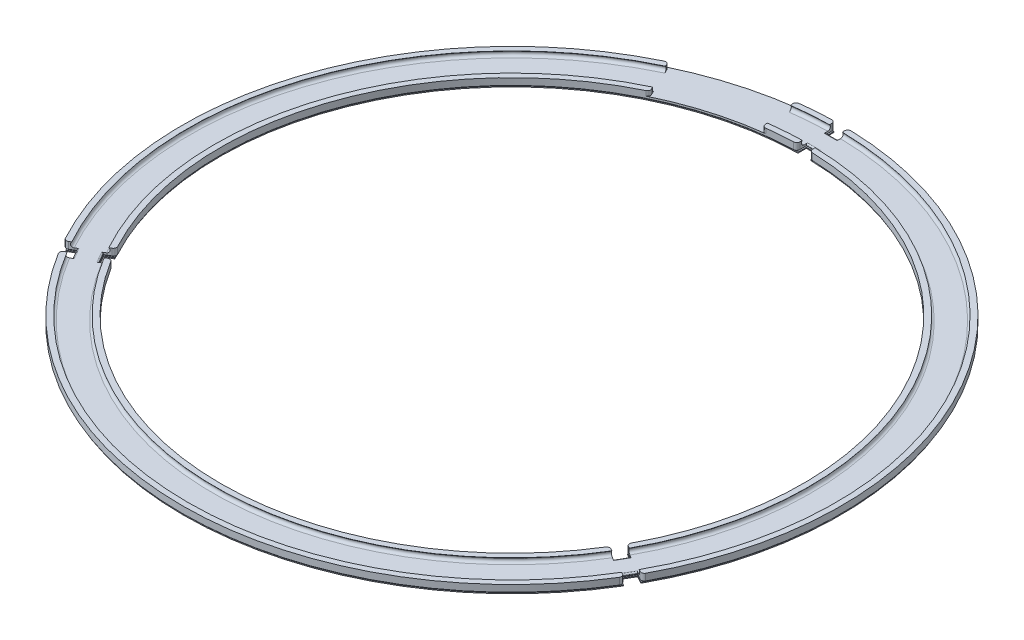
from build123d import *
from build123d.topology import SkipClean

# Parameters (mm, degrees)
CHAMFER1_SIZE                = 0.4
SKETCH10_R                   = 102.8
SKETCH10_R_2                 = 91.6
BOSS_EXTRUDE2_DEPTH          = 0.3
CUT_EXTRUDE5_DEPTH           = 146.962675023
FILLET4_R                    = 1
CHAMFER2_SIZE                = 0.4
FILLET6_R                    = 0.4
CIRPATTERN3_COUNT            = 3
FILLET4_OF_CIRPATTERN3_R     = 1
CHAMFER2_OF_CIRPATTERN3_SIZE = 0.4
FILLET6_OF_CIRPATTERN3_R     = 0.4
CUT_EXTRUDE6_DEPTH           = 146.954547721
FILLET5_R                    = 1


with BuildPart() as part:
    # Sketch1 → Revolve1 (revolve)
    with BuildSketch(Plane.XY, mode=Mode.PRIVATE) as revolve1_sk:
        with BuildLine():
            Line((91.2, 0.65), (92.952277442, 0.65))
            ThreePointArc((92.952277442, 0.65), (92.701564029, -0.291547595), (93.5, -0.85))
            Line((93.5, -0.85), (100.9, -0.85))
            ThreePointArc((100.9, -0.85), (101.698435971, -0.291547595), (101.447722558, 0.65))
            Line((101.447722558, 0.65), (103.2, 0.65))
            Line((103.2, 0.65), (103.2, -1.85))
            Line((103.2, -1.85), (91.2, -1.85))
            Line((91.2, -1.85), (91.2, 0.65))
        make_face()
    revolve(revolve1_sk.sketch.rotate(Axis((0, 52.631578947, 0), (0, -1, 0)), 90), axis=Axis((0, 52.631578947, 0), (0, -1, 0)))

    # Chamfer1
    chamfer1_edges = [part.edges().sort_by_distance(p)[0] for p in [
        (0, -1.85, -91.2),
        (0, -1.85, -103.2),
    ]]
    chamfer(chamfer1_edges, length=CHAMFER1_SIZE)


with BuildPart() as body_2:
    # Sketch10 → Boss-Extrude2 (new body)
    with BuildSketch(Plane.XZ.offset(1.85)):
        with Locations(Location((0, 0, 0), (0, 0, 270))):
            Circle(SKETCH10_R)
        with Locations(Location((0, 0, 0), (0, 0, 270))):
            Circle(SKETCH10_R_2, mode=Mode.SUBTRACT)
    extrude(amount=BOSS_EXTRUDE2_DEPTH)


with BuildPart() as cut_extrude5_tool:
    # Sketch11 → Cut-Extrude5 (new, symmetric)
    with BuildSketch(Plane(origin=(0, 0, 0), x_dir=(1, 0, 0), z_dir=(0, 1, 0))):
        with BuildLine():
            Line((-2, 103.180618335), (-2, 100.179342937))
            Line((-2, 100.179342937), (2, 100.179342937))
            Line((2, 100.179342937), (2, 103.180618335))
            ThreePointArc((2, 103.180618335), (0, 103.2), (-2, 103.180618335))
        make_face()
        with BuildLine():
            Line((-2, 91.178067538), (-2, 94.179342937))
            Line((-2, 94.179342937), (2, 94.179342937))
            Line((2, 94.179342937), (2, 91.178067538))
            ThreePointArc((2, 91.178067538), (0, 91.2), (-2, 91.178067538))
        make_face()
    cut_extrude5 = extrude(amount=CUT_EXTRUDE5_DEPTH, both=True)


with BuildPart() as part_1:
    add(part.part)

    # Cut-Extrude5: cut by cut_extrude5_tool
    add(cut_extrude5_tool.part, mode=Mode.SUBTRACT)

    # Fillet4
    fillet4_edges = [part_1.edges().sort_by_distance(p)[0] for p in [
        (2, -0.4, -103.180618335),
        (2, -0.4, -91.178067538),
        (-2, -0.4, -103.180618335),
        (-2, -0.4, -91.178067538),
    ]]
    fillet(fillet4_edges, radius=FILLET4_R)

    # Chamfer2
    chamfer2_edges = [part_1.edges().sort_by_distance(p)[0] for p in [
        (-2.055417439, -1.85, -102.48423315),
        (2.055417439, -1.85, -102.48423315),
        (-2, -1.85, -101.167651068),
        (0, -1.85, -100.179342937),
        (2, -1.85, -101.167651068),
        (-2.046952611, -1.85, -91.848358942),
        (2.046952611, -1.85, -91.848358942),
        (-2, -1.85, -93.165261535),
        (0, -1.85, -94.179342937),
        (2, -1.85, -93.165261535),
    ]]
    chamfer(chamfer2_edges, length=CHAMFER2_SIZE)

    # Fillet6
    fillet6_edges = [part_1.edges().sort_by_distance(p)[0] for p in [
        (0, -0.85, -100.179342937),
        (0, -0.85, -94.179342937),
    ]]
    fillet(fillet6_edges, radius=FILLET6_R)


with BuildPart() as body_2_1:
    add(body_2.part)

    # Cut-Extrude5: cut by cut_extrude5_tool
    add(cut_extrude5_tool.part, mode=Mode.SUBTRACT)


with BuildPart() as cirpattern3_tool:
    # CirPattern3: Cut-Extrude5 ×3 about axis
    with SkipClean():  # the faces are left unmerged after this step: merging them gives an invalid solid
        cirpattern3_axis = Axis((0, 0, 0), (0, 1, 0))
        for i in range(1, CIRPATTERN3_COUNT):
            add(cut_extrude5.rotate(cirpattern3_axis, i * 360 / CIRPATTERN3_COUNT))


with BuildPart() as part_2:
    with SkipClean():  # the faces are left unmerged after this step: merging them gives an invalid solid
        add(part_1.part)

        # CirPattern3: cut by cirpattern3_tool
        add(cirpattern3_tool.part, mode=Mode.SUBTRACT)

    # Fillet4 of CirPattern3
    fillet4_of_cirpattern3_edges = [part_2.edges().sort_by_distance(p)[0] for p in [
        (-90.357036656, -0.4, 49.85825836),
        (-79.962522756, -0.4, 43.856982962),
        (-88.357036656, -0.4, 53.322359975),
        (-77.962522756, -0.4, 47.321084577),
        (88.357036656, -0.4, 53.322359975),
        (77.962522756, -0.4, 47.321084577),
        (90.357036656, -0.4, 49.85825836),
        (79.962522756, -0.4, 43.856982962),
    ]]
    fillet(fillet4_of_cirpattern3_edges, radius=FILLET4_OF_CIRPATTERN3_R)

    # Chamfer2 of CirPattern3
    chamfer2_of_cirpattern3_edges = [part_2.edges().sort_by_distance(p)[0] for p in [
        (-87.726240675, -1.85, 53.022160293),
        (-89.781658115, -1.85, 49.462072857),
        (-86.613755866, -1.85, 52.315876342),
        (-86.757855918, -1.85, 50.089671468),
        (-88.613755866, -1.85, 48.851774726),
        (-78.519535835, -1.85, 47.696892432),
        (-80.566488445, -1.85, 44.15146651),
        (-79.68348324, -1.85, 48.314681575),
        (-81.561703495, -1.85, 47.089671468),
        (-81.68348324, -1.85, 44.85057996),
        (89.781658115, -1.85, 49.462072857),
        (87.726240675, -1.85, 53.022160293),
        (88.613755866, -1.85, 48.851774726),
        (86.757855918, -1.85, 50.089671468),
        (86.613755866, -1.85, 52.315876342),
        (80.566488445, -1.85, 44.15146651),
        (78.519535835, -1.85, 47.696892432),
        (81.68348324, -1.85, 44.85057996),
        (81.561703495, -1.85, 47.089671468),
        (79.68348324, -1.85, 48.314681575),
    ]]
    chamfer(chamfer2_of_cirpattern3_edges, length=CHAMFER2_OF_CIRPATTERN3_SIZE)

    # Fillet6 of CirPattern3
    fillet6_of_cirpattern3_edges = [part_2.edges().sort_by_distance(p)[0] for p in [
        (-86.757855918, -0.85, 50.089671468),
        (-81.561703495, -0.85, 47.089671468),
        (86.757855918, -0.85, 50.089671468),
        (81.561703495, -0.85, 47.089671468),
    ]]
    fillet(fillet6_of_cirpattern3_edges, radius=FILLET6_OF_CIRPATTERN3_R)

    # Sketch12 → Cut-Extrude6 (cut, through all)
    with BuildSketch(Plane(origin=(0, -0.85, 0), x_dir=(1, 0, 0), z_dir=(0, 1, 0))):
        with BuildLine():
            Line((-44.264367341, 93.225027669), (0, 0))
            Line((0, 0), (-13.578947368, 102.302747707))
            ThreePointArc((-13.578947368, 102.302747707), (-29.275647122, 98.960479413), (-44.264367341, 93.225027669))
        make_face()
    extrude(amount=CUT_EXTRUDE6_DEPTH, mode=Mode.SUBTRACT)

    # Fillet5
    fillet5_edges = [part_2.edges().sort_by_distance(p)[0] for p in [
        (-13.578947368, -0.1, -102.302747707),
        (-44.264367341, -0.1, -93.225027669),
        (-39.117347883, -0.1, -82.384908173),
        (-12, -0.1, -90.407079369),
    ]]
    fillet(fillet5_edges, radius=FILLET5_R)


with BuildPart() as body_2_2:
    with SkipClean():  # the faces are left unmerged after this step: merging them gives an invalid solid
        add(body_2_1.part)

        # CirPattern3: cut by cirpattern3_tool
        add(cirpattern3_tool.part, mode=Mode.SUBTRACT)


solid = Compound([part_2.part, body_2_2.part])
